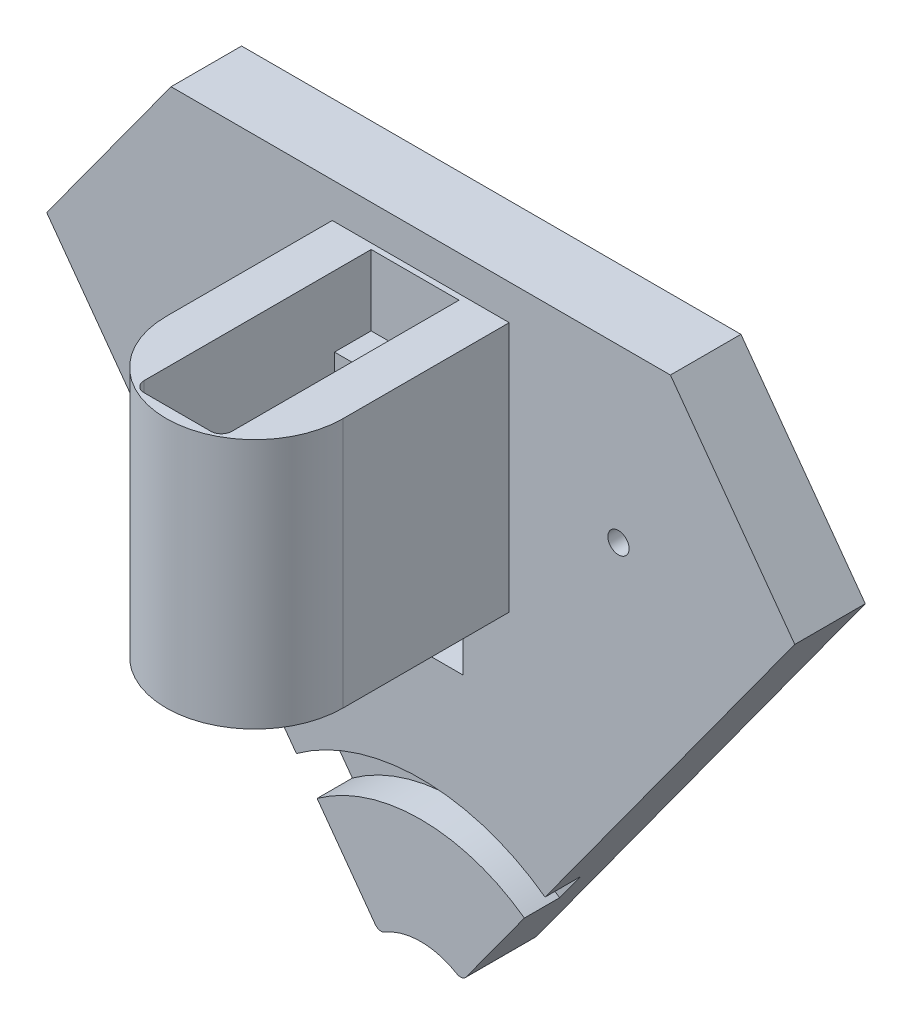
from build123d import *

# Parameters (mm, degrees)
SKETCH4_W                = 12.46
SKETCH4_H                = 17.25
BOSS_EXTRUDE3_DEPTH      = 6
SKETCH8_R                = 12.546781182
SKETCH8_R_2              = 11.15
BOSS_EXTRUDE6_DEPTH      = 8.3
BOSS_EXTRUDE6_DEPTH_BACK = 17.25
BOSS_EXTRUDE4_DEPTH      = 17.25
SKETCH6_R                = 0.75
CUT_EXTRUDE1_DEPTH       = 5
CHAMFER1_SIZE            = 0.5
CHAMFER1_SIZE2           = 0.866025404
SKETCH10_W               = 12.46
SKETCH10_H               = 23.7
CUT_EXTRUDE3_DEPTH       = 17.25
BOSS_EXTRUDE7_DEPTH      = 8.3
BOSS_EXTRUDE9_DEPTH      = 10
SKETCH16_R               = 11.15
SKETCH16_R_2             = 7.2
BOSS_EXTRUDE10_DEPTH     = 8.3
SKETCH17_R               = 10.2
SKETCH17_R_2             = 7.2
CUT_EXTRUDE5_DEPTH       = 1.3
SKETCH11_W               = 10
SKETCH11_H               = 2
CUT_EXTRUDE4_DEPTH       = 23.7
CUT_EXTRUDE7_REACH       = 37.55
SKETCH19_W               = 12.46
SKETCH19_H               = 6
OFFSET_R_DEPTH           = 10
SKETCH21_R               = 30
SKETCH21_R_2             = 25
CUT_EXTRUDE9_DEPTH       = 5
SKETCH22_W               = 12
SKETCH22_H               = 6
CUT_EXTRUDE10_DEPTH      = 11
SKETCH20_R               = 10
CUT_EXTRUDE8_DEPTH       = 10
FILLET1_R                = 1
CUT_EXTRUDE11_DEPTH      = 11
SKETCH24_R               = 0.75
CUT_EXTRUDE12_DEPTH      = 11
SKETCH25_R               = 1.5
CUT_EXTRUDE13_DEPTH      = 7


with BuildPart() as part:
    # Sketch4 → Boss-Extrude3 (new body)
    with BuildSketch(Plane.XY):
        with Locations((0, -1.35)):
            Rectangle(SKETCH4_W, SKETCH4_H)
    extrude(amount=BOSS_EXTRUDE3_DEPTH)



with BuildPart() as body_2:
    # Sketch8 → Boss-Extrude6 (new body, two sides)
    with BuildSketch(Plane(origin=(0, -9.975, 0), x_dir=(-1, 0, 0), z_dir=(0, -1, 0))) as boss_extrude6_sk:
        with Locations((0, -23.55)):
            Circle(SKETCH8_R)
        with Locations((0, -23.55)):
            Circle(SKETCH8_R_2, mode=Mode.SUBTRACT)
    extrude(amount=BOSS_EXTRUDE6_DEPTH)
    extrude(boss_extrude6_sk.sketch, amount=-BOSS_EXTRUDE6_DEPTH_BACK)


with BuildPart() as part_1:
    add(part.part)

    add(body_2.part)  # Boss-Extrude4 merges body 2
    # Sketch5 → Boss-Extrude4 (add)
    with BuildSketch(Plane(origin=(0, 7.275, 0), x_dir=(1, 0, 0), z_dir=(0, 1, 0))):
        with BuildLine():
            Line((12.546781182, -23.55), (12.546781182, 0))
            Line((12.546781182, 0), (6.23, 0))
            Line((6.23, 0), (6.23, -29.7))
            Line((6.23, -29.7), (-6.23, -29.7))
            Line((-6.23, -29.7), (-6.23, 0))
            Line((-6.23, 0), (-12.546781182, 0))
            Line((-12.546781182, 0), (-12.546781182, -23.55))
            ThreePointArc((-12.546781182, -23.55), (0, -36.096781182), (12.546781182, -23.55))
        make_face()
    extrude(amount=-BOSS_EXTRUDE4_DEPTH)

    # Sketch6 → Cut-Extrude1 (cut)
    with BuildSketch(Plane(origin=(0, 7.275, 0), x_dir=(1, 0, 0), z_dir=(0, 1, 0))):
        with Locations((0, -3.6)):
            Circle(SKETCH6_R)
        with Locations((0, -32.1)):
            Circle(SKETCH6_R)
    extrude(amount=-CUT_EXTRUDE1_DEPTH, mode=Mode.SUBTRACT)

    # Chamfer1
    chamfer1_edges = [part_1.edges().sort_by_distance(p)[0] for p in [
        (-0.75, 7.275, 3.6),
        (-0.75, 7.275, 32.1),
    ]]
    chamfer1_side = [part_1.faces().sort_by_distance(p)[0] for p in [
        (0, 7.275, 35.657160381),
    ]]
    chamfer(chamfer1_edges, length=CHAMFER1_SIZE, length2=CHAMFER1_SIZE2, reference=chamfer1_side[0])

    # Sketch10 → Cut-Extrude3 (cut)
    with BuildSketch(Plane(origin=(0, 7.275, 0), x_dir=(1, 0, 0), z_dir=(0, 1, 0))):
        with Locations((0, -17.85)):
            Rectangle(SKETCH10_W, SKETCH10_H)
    extrude(amount=-CUT_EXTRUDE3_DEPTH, mode=Mode.SUBTRACT)

    # Sketch13 → Boss-Extrude7 (add)
    with BuildSketch(Plane.XZ.offset(18.275)):
        with BuildLine():
            Line((-12.546781182, 23.55), (-12.546781182, 0))
            Line((-12.546781182, 0), (12.546781182, 0))
            Line((12.546781182, 0), (12.546781182, 23.55))
            ThreePointArc((12.546781182, 23.55), (0, 11.003218818), (-12.546781182, 23.55))
        make_face()
    extrude(amount=-BOSS_EXTRUDE7_DEPTH)

    # Sketch15 → Boss-Extrude9 (add)
    with BuildSketch(Plane(origin=(0, 7.275, 0), x_dir=(1, 0, 0), z_dir=(0, 1, 0))):
        with BuildLine():
            Line((-12.546781182, 0), (12.546781182, 0))
            Line((12.546781182, 0), (12.546781182, -23.55))
            ThreePointArc((12.546781182, -23.55), (0, -36.096781182), (-12.546781182, -23.55))
            Line((-12.546781182, -23.55), (-12.546781182, 0))
        make_face()
        with BuildLine():
            Line((-6.23, -0.8), (6.23, -0.8))
            Line((6.23, -0.8), (6.23, -33))
            ThreePointArc((6.23, -33), (5.790660172, -34.060660172), (4.73, -34.5))
            Line((4.73, -34.5), (-4.73, -34.5))
            ThreePointArc((-4.73, -34.5), (-5.790660172, -34.060660172), (-6.23, -33))
            Line((-6.23, -33), (-6.23, -0.8))
        make_face(mode=Mode.SUBTRACT)
    extrude(amount=BOSS_EXTRUDE9_DEPTH)

    # Sketch16 → Boss-Extrude10 (add)
    with BuildSketch(Plane.XZ.offset(18.275)):
        with Locations((0, 23.55)):
            Circle(SKETCH16_R)
        with Locations((0, 23.55)):
            Circle(SKETCH16_R_2, mode=Mode.SUBTRACT)
    extrude(amount=-BOSS_EXTRUDE10_DEPTH)

    # Sketch17 → Cut-Extrude5 (cut)
    with BuildSketch(Plane.XZ.offset(18.275)):
        with Locations((0, 23.55)):
            Circle(SKETCH17_R)
        with Locations((0, 23.55)):
            Circle(SKETCH17_R_2, mode=Mode.SUBTRACT)
    extrude(amount=-CUT_EXTRUDE5_DEPTH, mode=Mode.SUBTRACT)

    # Sketch11 → Cut-Extrude4 (cut)
    with BuildSketch(Plane.XY.offset(29.7)):
        with Locations((0, -10.975)):
            Rectangle(SKETCH11_W, SKETCH11_H)
    extrude(amount=-CUT_EXTRUDE4_DEPTH, mode=Mode.SUBTRACT)

    # Sketch19 → Cut-Extrude7 (cut, up to next)
    with BuildSketch(Plane.XZ.offset(18.275), mode=Mode.PRIVATE) as cut_extrude7_sk1:
        with Locations((0, 9)):
            Rectangle(SKETCH19_W, SKETCH19_H)
    cut_extrude7_tool1 = extrude(cut_extrude7_sk1.sketch, amount=-CUT_EXTRUDE7_REACH, mode=Mode.PRIVATE) & part_1.part
    add(cut_extrude7_tool1.solids().sort_by_distance((0, -18.275, 9))[0], mode=Mode.SUBTRACT)

    # Sketch1 → Offset R (add)
    with BuildSketch(Plane.XY):
        Polygon((0, -75), (70.674424412, 22.275), (-70.674424412, 22.275), align=None)
    extrude(amount=-OFFSET_R_DEPTH)

    # Sketch21 → Cut-Extrude9 (cut)
    with BuildSketch(Plane.XY):
        with Locations((0, -75)):
            Circle(SKETCH21_R)
        with Locations((0, -75)):
            Circle(SKETCH21_R_2, mode=Mode.SUBTRACT)
    extrude(amount=-CUT_EXTRUDE9_DEPTH, mode=Mode.SUBTRACT)

    # Sketch22 → Cut-Extrude10 (cut, through all)
    with BuildSketch(Plane.XY):
        with Locations((0, -26.275)):
            Rectangle(SKETCH22_W, SKETCH22_H)
    extrude(amount=-CUT_EXTRUDE10_DEPTH, mode=Mode.SUBTRACT)

    # Sketch20 → Cut-Extrude8 (cut)
    with BuildSketch(Plane.XY):
        with Locations((0, -75)):
            Circle(SKETCH20_R)
    extrude(amount=-CUT_EXTRUDE8_DEPTH, mode=Mode.SUBTRACT)

    # Fillet1
    fillet1_edges = [part_1.edges().sort_by_distance(p)[0] for p in [
        (5.877852523, -66.909830056, -5),
        (-5.877852523, -66.909830056, -5),
    ]]
    fillet(fillet1_edges, radius=FILLET1_R)

    # Sketch23 → Cut-Extrude11 (cut, through all)
    with BuildSketch(Plane.XY):
        Polygon((-35.407309274, 22.275), (-53.040866843, -1.995509831), (-70.674424412, 22.275), align=None)
        Polygon((70.674424412, 22.275), (35.407309274, 22.275), (53.040866843, -1.995509831), align=None)
    extrude(amount=-CUT_EXTRUDE11_DEPTH, mode=Mode.SUBTRACT)

    # Sketch24 → Cut-Extrude12 (cut, through all)
    with BuildSketch(Plane.XY):
        with Locations((-28.040866843, -1.995509831)):
            Circle(SKETCH24_R)
        with Locations((28.040866843, -1.995509831)):
            Circle(SKETCH24_R)
    extrude(amount=-CUT_EXTRUDE12_DEPTH, mode=Mode.SUBTRACT)

    # Sketch25 → Cut-Extrude13 (cut)
    with BuildSketch(Plane.XY):
        with Locations((-28.040866843, -1.995509831)):
            Circle(SKETCH25_R)
        with Locations((28.040866843, -1.995509831)):
            Circle(SKETCH25_R)
    extrude(amount=-CUT_EXTRUDE13_DEPTH, mode=Mode.SUBTRACT)


solid = part_1.part
